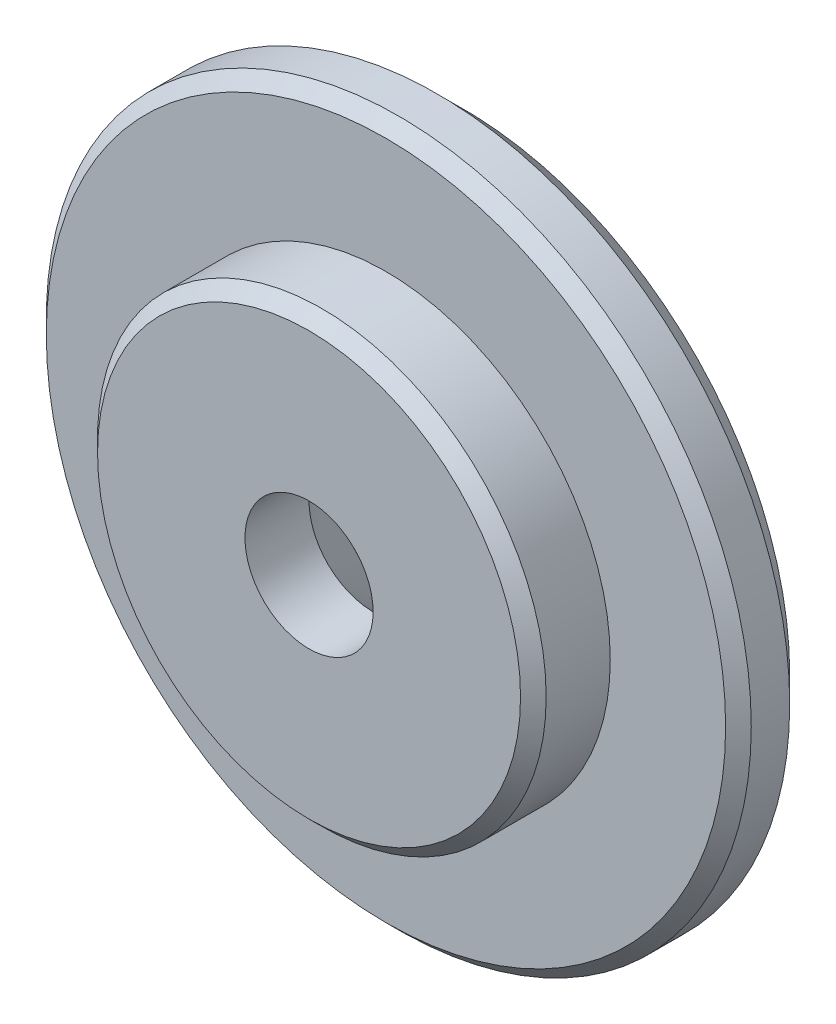
from build123d import *

# Parameters (mm, degrees)
CHAFL_N1_SIZE = 2
CHAFL_N2_SIZE = 1


with BuildPart() as part:
    # Croquis1 → Revolución1 (revolve)
    with BuildSketch(Plane(origin=(0, 0, 0), x_dir=(1, 0, 0), z_dir=(0, 1, 0))):
        Polygon((17.512143261, -5.969981855), (27.512147725, -5.969981855), (27.512147725, 0.030018145), (12.012147715, 0.030018145), (5.012147715, -6.969981855), (5.012147715, -11.969981855), (17.512143261, -11.969981855), align=None)
    revolve(axis=Axis((0.012147715, 0, 0), (0, 0, 1)))

    # Chaflán1
    chafl_n1_edges = [part.edges().sort_by_distance(p)[0] for p in [
        (-27.487852294, 0, -0.030018145),
    ]]
    chamfer(chafl_n1_edges, length=CHAFL_N1_SIZE)

    # Chaflán2
    chafl_n2_edges = [part.edges().sort_by_distance(p)[0] for p in [
        (-27.487852294, 0, 5.969981855),
        (-17.48784783, 0, 11.969981855),
    ]]
    chamfer(chafl_n2_edges, length=CHAFL_N2_SIZE)


solid = part.part
